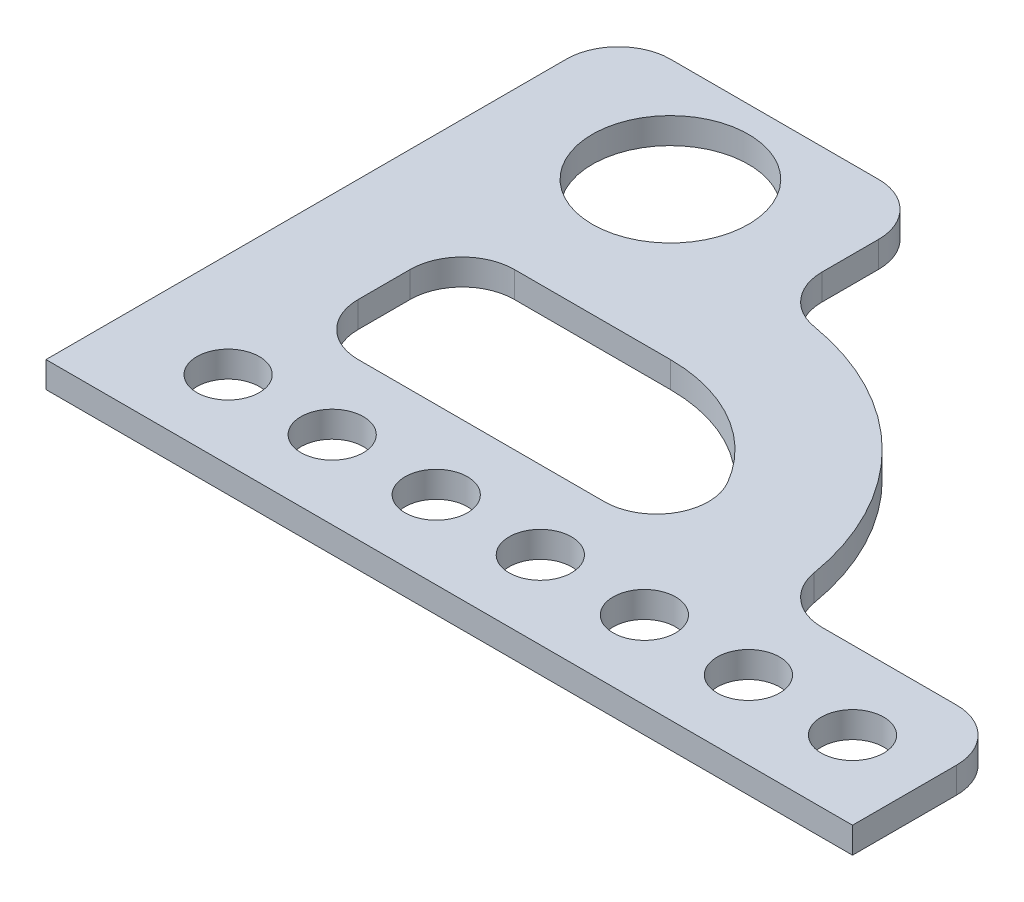
from build123d import *

# Parameters (mm, degrees)
SKETCH1_R           = 6
SKETCH1_R_2         = 15
BOSS_EXTRUDE1_DEPTH = 5


with BuildPart() as part:
    # Sketch1 → Boss-Extrude1 (new body)
    with BuildSketch(Plane(origin=(0, 0, 0), x_dir=(1, 0, 0), z_dir=(0, 1, 0))):
        with BuildLine():
            Line((0, 0), (155, 0))
            Line((155, 0), (155, 20))
            ThreePointArc((155, 20), (152.071067812, 27.071067812), (145, 30))
            Line((145, 30), (119.160797831, 30))
            ThreePointArc((119.160797831, 30), (112.705825587, 32.362373842), (109.300664859, 38.333333333))
            ThreePointArc((109.300664859, 38.333333333), (95.355339059, 65.355339059), (68.333333333, 79.300664859))
            ThreePointArc((68.333333333, 79.300664859), (62.362373842, 82.705825587), (60, 89.160797831))
            Line((60, 89.160797831), (60, 100))
            ThreePointArc((60, 100), (57.071067812, 107.071067812), (50, 110))
            Line((50, 110), (10, 110))
            ThreePointArc((10, 110), (2.928932188, 107.071067812), (0, 100))
            Line((0, 100), (0, 0))
        make_face()
        with Locations((20, 15)):
            Circle(SKETCH1_R, mode=Mode.SUBTRACT)
        with Locations((40, 15)):
            Circle(SKETCH1_R, mode=Mode.SUBTRACT)
        with Locations((60, 15)):
            Circle(SKETCH1_R, mode=Mode.SUBTRACT)
        with Locations((80, 15)):
            Circle(SKETCH1_R, mode=Mode.SUBTRACT)
        with Locations((100, 15)):
            Circle(SKETCH1_R, mode=Mode.SUBTRACT)
        with Locations((120, 15)):
            Circle(SKETCH1_R, mode=Mode.SUBTRACT)
        with Locations((140, 15)):
            Circle(SKETCH1_R, mode=Mode.SUBTRACT)
        with Locations((30, 90)):
            Circle(SKETCH1_R_2, mode=Mode.SUBTRACT)
        with BuildLine():
            Line((60, 60), (30, 60))
            ThreePointArc((30, 60), (22.928932188, 57.071067812), (20, 50))
            Line((20, 50), (20, 40))
            ThreePointArc((20, 40), (22.928932188, 32.928932188), (30, 30))
            Line((30, 30), (77.320508076, 30))
            ThreePointArc((77.320508076, 30), (85.980762114, 35), (85.980762114, 45))
            ThreePointArc((85.980762114, 45), (75, 55.980762114), (60, 60))
        make_face(mode=Mode.SUBTRACT)
    extrude(amount=BOSS_EXTRUDE1_DEPTH)


solid = part.part
